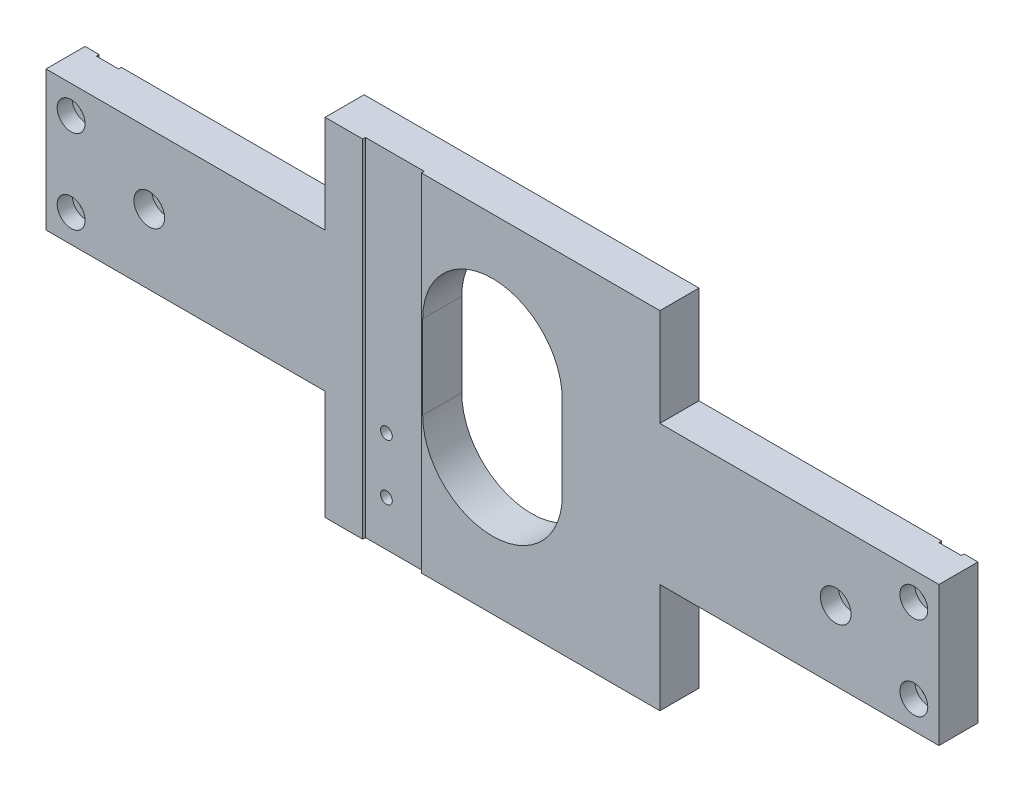
from build123d import *

# Parameters (mm, degrees)
SKETCH_1_W                   = 320
SKETCH_1_H                   = 50
EXTRUDE_1_DEPTH              = 14
HOLE_WIZARD_M6_1_D           = 6.6
HOLE_WIZARD_M6_1_CBORE_D     = 11
HOLE_WIZARD_M6_1_CBORE_DEPTH = 6.4
SKETCH_5_R                   = 6
CUT_EXTRUDE_1_DEPTH          = 3
SKETCH_6_W                   = 8
SKETCH_6_H                   = 50
CUT_EXTRUDE_2_DEPTH          = 1
HOLE_WIZARD_M5_1_D           = 5.5
HOLE_WIZARD_M5_1_CBORE_D     = 10
HOLE_WIZARD_M5_1_CBORE_DEPTH = 5.4
SKETCH_9_W                   = 30
SKETCH_9_H                   = 14
CUT_EXTRUDE_3_DEPTH          = 15
SKETCH_10_W                  = 120
SKETCH_10_H                  = 100
SKETCH_10_R                  = 39
EXTRUDE_2_DEPTH              = 14
SKETCH_15_R                  = 39
EXTRUDE_3_DEPTH              = 14
CUT_EXTRUDE_4_DEPTH          = 31.5
SKETCH_17_W                  = 120
SKETCH_17_H                  = 14
EXTRUDE_4_DEPTH              = 14.2
SKETCH_18_W                  = 120
SKETCH_18_H                  = 14
EXTRUDE_5_DEPTH              = 10
HOLE_WIZARD_M5_1_2_D         = 4.2
HOLE_WIZARD_M5_1_2_DEPTH     = 12.4
HOLE_WIZARD_M5_1_2_TIP       = 1.2618073
SKETCH_21_W                  = 21
SKETCH_21_H                  = 124.2
CUT_EXTRUDE_5_DEPTH          = 1
HOLE_WIZARD_M5_2_D           = 4.2
HOLE_WIZARD_M5_2_DEPTH       = 12.4
HOLE_WIZARD_M5_2_TIP         = 1.2618073


with BuildPart() as part:
    # 草图1 → 凸台-拉伸1 (new body)
    with BuildSketch(Plane.XY):
        with Locations((160, 25)):
            Rectangle(SKETCH_1_W, SKETCH_1_H)
    extrude(amount=EXTRUDE_1_DEPTH)

    # M6 六角凹头螺钉的柱形沉头孔1 (through all)
    with Locations(Plane.XY.offset(14)):
        with Locations((283, 25), (37, 25)):
            CounterBoreHole(HOLE_WIZARD_M6_1_D / 2, HOLE_WIZARD_M6_1_CBORE_D / 2, HOLE_WIZARD_M6_1_CBORE_DEPTH)

    # 草图5 → 切除-拉伸1 (cut)
    with BuildSketch(Plane(origin=(0, 0, 0), x_dir=(-1, 0, 0), z_dir=(0, 0, -1))):
        with Locations((-283, 25)):
            Circle(SKETCH_5_R)
        with Locations((-37, 25)):
            Circle(SKETCH_5_R)
    extrude(amount=-CUT_EXTRUDE_1_DEPTH, mode=Mode.SUBTRACT)

    # 草图6 → 切除-拉伸2 (cut)
    with BuildSketch(Plane(origin=(0, 0, 0), x_dir=(-1, 0, 0), z_dir=(0, 0, -1))):
        with Locations((-9, 25)):
            Rectangle(SKETCH_6_W, SKETCH_6_H)
        with Locations((-311, 25)):
            Rectangle(SKETCH_6_W, SKETCH_6_H)
    extrude(amount=-CUT_EXTRUDE_2_DEPTH, mode=Mode.SUBTRACT)

    # Hole Wizard M5 _1 (through all)
    with Locations(Plane.XY.offset(14)):
        with Locations((311, 10), (311, 40), (9, 40), (9, 10)):
            CounterBoreHole(HOLE_WIZARD_M5_1_D / 2, HOLE_WIZARD_M5_1_CBORE_D / 2, HOLE_WIZARD_M5_1_CBORE_DEPTH)

    # 草图9 → 切除-拉伸3 (cut)
    with BuildSketch(Plane.XZ):
        with Locations((160, 7)):
            Rectangle(SKETCH_9_W, SKETCH_9_H)
    extrude(amount=-CUT_EXTRUDE_3_DEPTH, mode=Mode.SUBTRACT)

    # 草图10 → 凸台-拉伸2 (add)
    with BuildSketch(Plane.XY.offset(14)):
        with Locations((160, 25)):
            Rectangle(SKETCH_10_W, SKETCH_10_H)
        with Locations((160, 25)):
            Circle(SKETCH_10_R, mode=Mode.SUBTRACT)
    extrude(amount=-EXTRUDE_2_DEPTH)

    # 草图15 → 凸台-拉伸3 (add)
    with BuildSketch(Plane.XY.offset(14)):
        with Locations((160, 25)):
            Circle(SKETCH_15_R)
    extrude(amount=-EXTRUDE_3_DEPTH)

    # 草图16 → 切除-拉伸4 (cut)
    with BuildSketch(Plane.XY.offset(14)):
        with BuildLine():
            Line((185, 10), (185, 40))
            ThreePointArc((185, 40), (160, 65), (135, 40))
            Line((135, 40), (135, 10))
            ThreePointArc((135, 10), (160, -15), (185, 10))
        make_face()
    extrude(amount=-CUT_EXTRUDE_4_DEPTH, mode=Mode.SUBTRACT)

    # 草图17 → 凸台-拉伸4 (add)
    with BuildSketch(Plane.XZ.offset(25)):
        with Locations((160, 7)):
            Rectangle(SKETCH_17_W, SKETCH_17_H)
    extrude(amount=EXTRUDE_4_DEPTH)

    # 草图18 → 凸台-拉伸5 (add)
    with BuildSketch(Plane(origin=(0, 75, 0), x_dir=(1, 0, 0), z_dir=(0, 1, 0))):
        with Locations((160, -7)):
            Rectangle(SKETCH_18_W, SKETCH_18_H)
    extrude(amount=EXTRUDE_5_DEPTH)

    # Hole Wizard M5 _1 2
    with Locations(Plane.XY.offset(14)):
        with Locations((121, -3), (121, -23)):
            Hole(HOLE_WIZARD_M5_1_2_D / 2, depth=HOLE_WIZARD_M5_1_2_DEPTH)
            with Locations((0, 0, -(HOLE_WIZARD_M5_1_2_DEPTH + HOLE_WIZARD_M5_1_2_TIP / 2))):  # 118° drill point
                Cone(0, HOLE_WIZARD_M5_1_2_D / 2, HOLE_WIZARD_M5_1_2_TIP, mode=Mode.SUBTRACT)

    # 草图21 → 切除-拉伸5 (cut)
    with BuildSketch(Plane.XY.offset(14)):
        with Locations((124, 22.9)):
            Rectangle(SKETCH_21_W, SKETCH_21_H)
    extrude(amount=-CUT_EXTRUDE_5_DEPTH, mode=Mode.SUBTRACT)

    # M5 螺纹孔2
    with Locations(Plane(origin=(0, -39.2, 0), x_dir=(-1, 0, 0), z_dir=(0, -1, 0))):
        with Locations((-160, -7), (-110, -7), (-210, -7)):
            Hole(HOLE_WIZARD_M5_2_D / 2, depth=HOLE_WIZARD_M5_2_DEPTH)
            with Locations((0, 0, -(HOLE_WIZARD_M5_2_DEPTH + HOLE_WIZARD_M5_2_TIP / 2))):  # 118° drill point
                Cone(0, HOLE_WIZARD_M5_2_D / 2, HOLE_WIZARD_M5_2_TIP, mode=Mode.SUBTRACT)


solid = part.part
